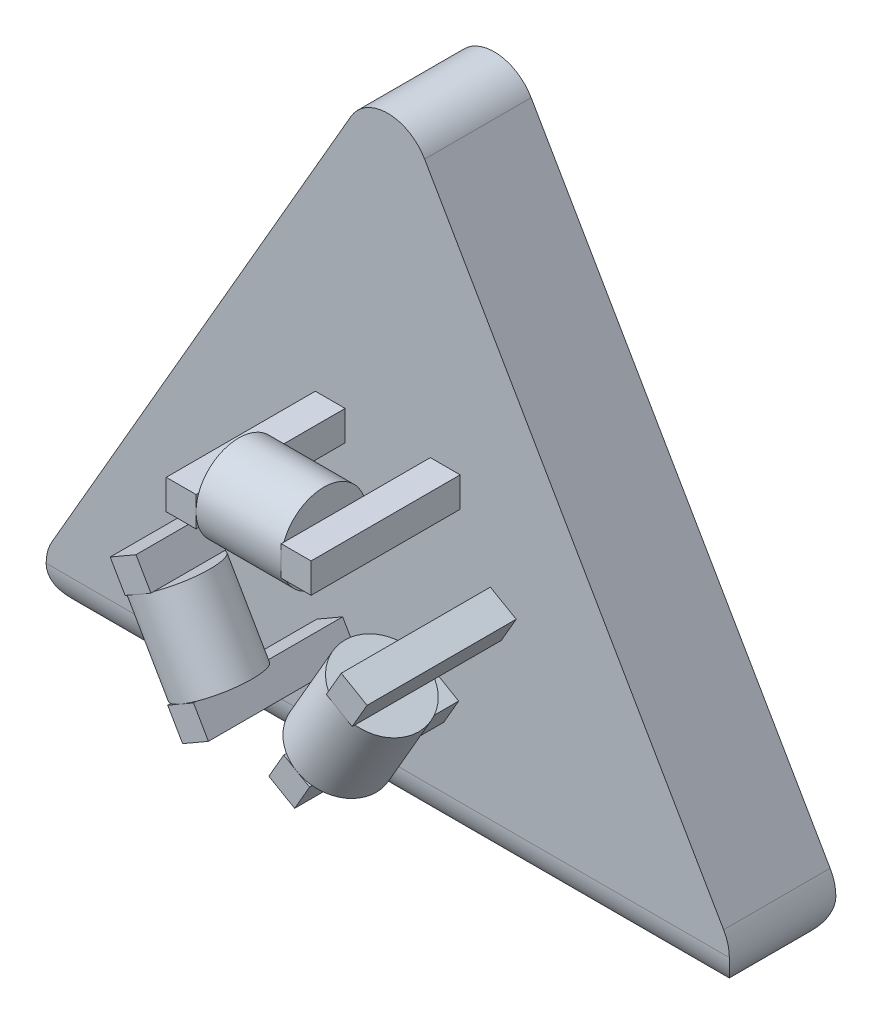
from build123d import *

# Parameters (mm, degrees)
EXTRUDE_1_DEPTH        = 10
FILLET_1_R             = 4
SKETCH_2_W             = 2.8
SKETCH_2_H             = 2.8
EXTRUDE_2_DEPTH        = 14
SKETCH_3_R             = 3.6
EXTRUDE_3_DEPTH        = 8
SKETCH_4_R             = 4
EXTRUDE_4_DEPTH        = 8
SKETCH_5_R             = 4
EXTRUDE_5_DEPTH        = 8
SKETCH_6_W             = 20
SKETCH_6_H             = 2
CUT_EXTRUDE_1_DEPTH    = 8
HOLE_WIZARD_M4_1_D     = 3.3
HOLE_WIZARD_M4_1_DEPTH = 5
HOLE_WIZARD_M4_1_TIP   = 0.991420021


with BuildPart() as part:
    # 草图1 → 凸台-拉伸1 (new body)
    with BuildSketch(Plane.XY):
        Polygon((0, 40), (35, -20.621778265), (-35, -20.621778265), align=None)
    extrude(amount=EXTRUDE_1_DEPTH)

    # 圆角1
    fillet_1_edges = [part.edges().sort_by_distance(p)[0] for p in [
        (0, -20.621778265, 10),
        (0, -20.621778265, 0),
        (35, -20.621778265, 5),
        (-35, -20.621778265, 5),
        (0, 40, 5),
    ]]
    fillet(fillet_1_edges, radius=FILLET_1_R)

    # 草图2 → 凸台-拉伸2 (add)
    with BuildSketch(Plane.XY.offset(10)):
        with Locations((-5.4, 8.6)):
            Rectangle(SKETCH_2_W, SKETCH_2_H)
        with Locations((5.4, 8.6)):
            Rectangle(SKETCH_2_W, SKETCH_2_H)
        Polygon((10.660254038, -1.535898385), (12.060254038, 0.888972746), (9.635382907, 2.288972746), (8.235382907, -0.135898385), align=None)
        Polygon((5.260254038, -10.888972746), (2.835382907, -9.488972746), (4.235382907, -7.064101615), (6.660254038, -8.464101615), align=None)
        Polygon((-6.660254038, -8.464101615), (-5.260254038, -10.888972746), (-2.835382907, -9.488972746), (-4.235382907, -7.064101615), align=None)
        Polygon((-12.060254038, 0.888972746), (-9.635382907, 2.288972746), (-8.235382907, -0.135898385), (-10.660254038, -1.535898385), align=None)
    extrude(amount=EXTRUDE_2_DEPTH)

    # 草图3 → 凸台-拉伸3 (add)
    with BuildSketch(Plane(origin=(-2, 3.464101615, 0), x_dir=(-0.866025404, -0.5, 0), z_dir=(0.5, -0.866025404, 0))):
        with Locations((8.6, -20.4)):
            Circle(SKETCH_3_R)
    extrude(amount=EXTRUDE_3_DEPTH)

    # 草图4 → 凸台-拉伸4 (add)
    with BuildSketch(Plane(origin=(-4, 0, 0), x_dir=(0, 0, -1), z_dir=(1, 0, 0))):
        with Locations((-20, 8.6)):
            Circle(SKETCH_4_R)
    extrude(amount=EXTRUDE_4_DEPTH)

    # 草图5 → 凸台-拉伸5 (add)
    with BuildSketch(Plane(origin=(2, 3.464101615, 0), x_dir=(-0.866025404, 0.5, 0), z_dir=(-0.5, -0.866025404, 0))):
        with Locations((-8.6, -20)):
            Circle(SKETCH_5_R)
    extrude(amount=EXTRUDE_5_DEPTH)

    # 草图6 → 切除-拉伸1 (cut)
    with BuildSketch(Plane(origin=(0, 0, 0), x_dir=(-1, 0, 0), z_dir=(0, 0, -1))):
        with Locations((0, -2)):
            Rectangle(SKETCH_6_W, SKETCH_6_H)
    extrude(amount=-CUT_EXTRUDE_1_DEPTH, mode=Mode.SUBTRACT)

    # M4 螺纹孔1
    with Locations(Plane(origin=(0, 0, 0), x_dir=(-1, 0, 0), z_dir=(0, 0, -1))):
        with Locations((-7.497367874, 10.020225249), (7.560370965, 10.020225249)):
            Hole(HOLE_WIZARD_M4_1_D / 2, depth=HOLE_WIZARD_M4_1_DEPTH)
            with Locations((0, 0, -(HOLE_WIZARD_M4_1_DEPTH + HOLE_WIZARD_M4_1_TIP / 2))):  # 118° drill point
                Cone(0, HOLE_WIZARD_M4_1_D / 2, HOLE_WIZARD_M4_1_TIP, mode=Mode.SUBTRACT)


solid = part.part
